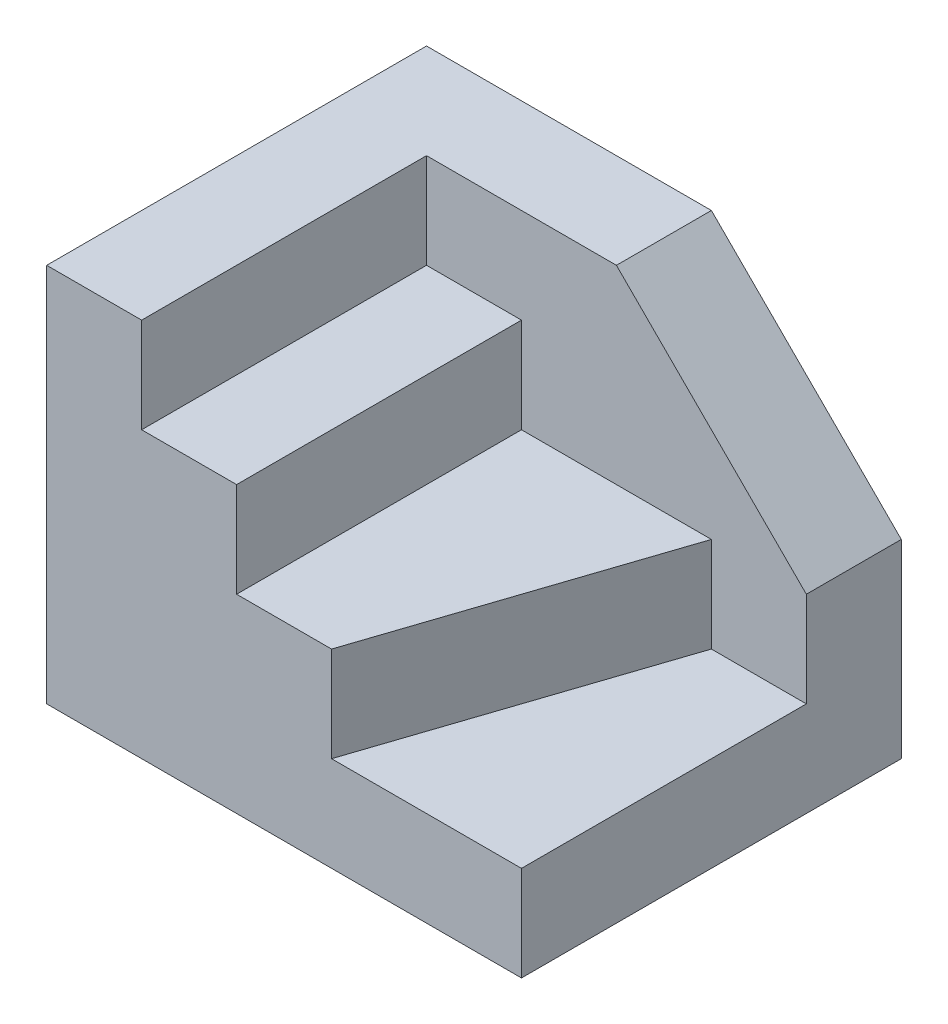
from build123d import *

# Parameters (mm, degrees)
SKETCH_1_W          = 5
SKETCH_1_H          = 4
EXTRUDE_1_DEPTH     = 1
EXTRUDE_2_DEPTH     = 2
SKETCH_1_4_W        = 1
SKETCH_1_4_H        = 3
EXTRUDE_3_DEPTH     = 3
EXTRUDE_4_DEPTH     = 4
CUT_EXTRUDE_1_DEPTH = 4


with BuildPart() as part:
    # 草圖1 → 填料-伸長1 (new body)
    with BuildSketch(Plane(origin=(0, 0, 0), x_dir=(1, 0, 0), z_dir=(0, 1, 0))):
        Rectangle(SKETCH_1_W, SKETCH_1_H)
    extrude(amount=EXTRUDE_1_DEPTH)

    # 草圖1<3> → 填料-伸長2 (add)
    with BuildSketch(Plane(origin=(0, 0, 0), x_dir=(1, 0, 0), z_dir=(0, 1, 0))):
        Polygon((0.5, -2), (1.5, 1), (-0.5, 1), (-0.5, -2), align=None)
    extrude(amount=EXTRUDE_2_DEPTH)

    # 草圖1<4> → 填料-伸長3 (add)
    with BuildSketch(Plane(origin=(0, 0, 0), x_dir=(1, 0, 0), z_dir=(0, 1, 0))):
        with Locations((-1, -0.5)):
            Rectangle(SKETCH_1_4_W, SKETCH_1_4_H)
    extrude(amount=EXTRUDE_3_DEPTH)

    # 草圖1<5> → 填料-伸長4 (add)
    with BuildSketch(Plane(origin=(0, 0, 0), x_dir=(1, 0, 0), z_dir=(0, 1, 0))):
        Polygon((1.5, 1), (2.5, 1), (2.5, 2), (-2.5, 2), (-2.5, -2), (-1.5, -2), (-1.5, 1), (-0.5, 1), align=None)
    extrude(amount=EXTRUDE_4_DEPTH)

    # 草圖2 → 除料-伸長1 (cut)
    with BuildSketch(Plane.XY.offset(-1)):
        Polygon((2.5, 4), (0.5, 4), (2.5, 2), align=None)
    extrude(amount=-CUT_EXTRUDE_1_DEPTH, mode=Mode.SUBTRACT)


solid = part.part
